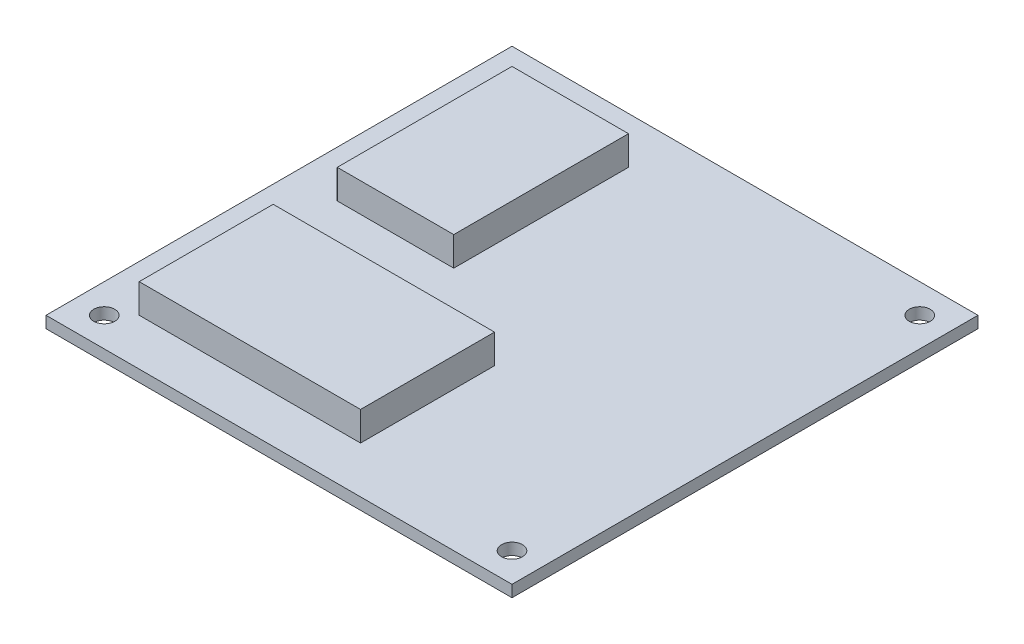
from build123d import *

# Parameters (mm, degrees)
SKETCH1_W              = 80
SKETCH1_H              = 80
PCB_DEPTH              = 2
SKETCH2_R              = 1.8
ATTACHMENT_HOLES_DEPTH = 3
LPATTERN1_COUNT        = 2
LPATTERN1_PITCH        = 70
LPATTERN1_COUNT_DIR2   = 2
LPATTERN1_PITCH_DIR2   = 70
SKETCH3_W              = 20
SKETCH3_H              = 30
GPS_DEPTH              = 5
SKETCH4_W              = 38
SKETCH4_H              = 23
IMU_DEPTH              = 5


with BuildPart() as part:
    # Sketch1 → PCB (new body)
    with BuildSketch(Plane(origin=(0, 0, 0), x_dir=(1, 0, 0), z_dir=(0, 1, 0))):
        with Locations((40, 40)):
            Rectangle(SKETCH1_W, SKETCH1_H)
    extrude(amount=PCB_DEPTH)

    # Sketch2 → Attachment Holes (cut, through all)
    with BuildSketch(Plane(origin=(0, 2, 0), x_dir=(1, 0, 0), z_dir=(0, 1, 0))):
        with Locations((5, 75)):
            Circle(SKETCH2_R)
    attachment_holes = extrude(amount=-ATTACHMENT_HOLES_DEPTH, mode=Mode.SUBTRACT)

    # LPattern1: Attachment Holes 2 × 2
    with Locations(*[(i * LPATTERN1_PITCH, 0, j * LPATTERN1_PITCH_DIR2) for i in range(LPATTERN1_COUNT) for j in range(LPATTERN1_COUNT_DIR2) if (i, j) != (0, 0)]):
        add(attachment_holes, mode=Mode.SUBTRACT)

    # Sketch3 → GPS (add)
    with BuildSketch(Plane(origin=(0, 2, 0), x_dir=(1, 0, 0), z_dir=(0, 1, 0))):
        with Locations((18, 57)):
            Rectangle(SKETCH3_W, SKETCH3_H)
    extrude(amount=GPS_DEPTH)

    # Sketch4 → IMU (add)
    with BuildSketch(Plane(origin=(0, 2, 0), x_dir=(1, 0, 0), z_dir=(0, 1, 0))):
        with Locations((27, 19.5)):
            Rectangle(SKETCH4_W, SKETCH4_H)
    extrude(amount=IMU_DEPTH)


solid = part.part
